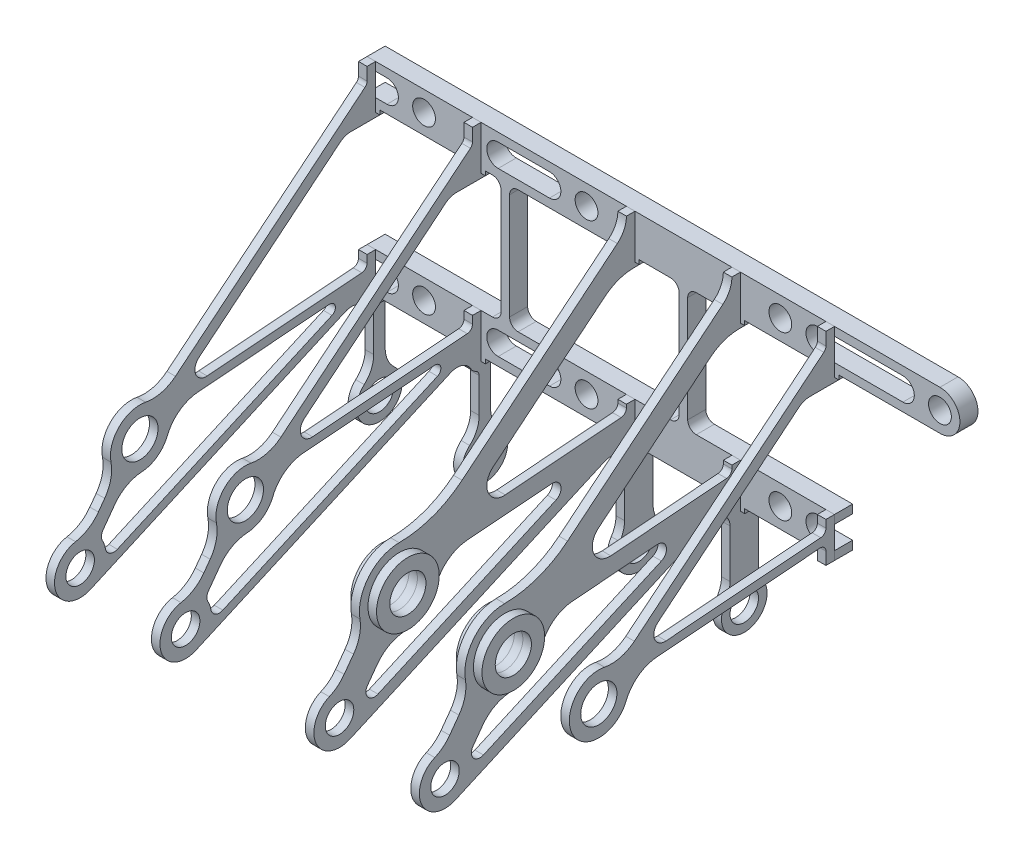
from build123d import *

# Parameters (mm, degrees)
SKETCH1_R                             = 4
BOSS_EXTRUDEMASTERCYLMNT_DEPTH        = 6.35
SKETCH7_R                             = 5
SKETCH7_R_2                           = 6.35
BOSS_EXTRUDEFLANGE1_DEPTH             = 3
BOSS_EXTRUDEFLANGE2_START             = -37
SKETCH7_2_R                           = 5
SKETCH7_2_R_2                         = 6.35
BOSS_EXTRUDEFLANGE2_DEPTH             = 3
BOSS_EXTRUDEFLANGE3_START             = -91
SKETCH7_3_R                           = 5
SKETCH7_3_R_2                         = 6.35
BOSS_EXTRUDEFLANGE3_DEPTH             = 3
BOSS_EXTRUDEFLANGE4_START             = -128
SKETCH7_4_R                           = 5
SKETCH7_4_R_2                         = 6.35
BOSS_EXTRUDEFLANGE4_DEPTH             = 3
BOSS_EXTRUDEFLANGE5_START             = -161
SKETCH7_5_R                           = 5
SKETCH7_5_R_2                         = 6.35
BOSS_EXTRUDEFLANGE5_DEPTH             = 3
SKETCH26_R                            = 11
SKETCH26_R_2                          = 6.35
BOSS_EXTRUDEBRAKEBUSH1_DEPTH          = 3
BOSS_EXTRUDEBRAKEBUSH2_START          = -3
SKETCH26_2_R                          = 11
SKETCH26_2_R_2                        = 6.35
BOSS_EXTRUDEBRAKEBUSH2_DEPTH          = 3
SKETCH27_R                            = 11
SKETCH27_R_2                          = 6.35
BOSS_EXTRUDEBRAKEBUSH3_DEPTH          = 3
BOSS_EXTRUDEBRAKEBUSH4_START          = -3
SKETCH27_2_R                          = 11
SKETCH27_2_R_2                        = 6.35
BOSS_EXTRUDEBRAKEBUSH4_DEPTH          = 3
CUT_EXTRUDELIGHTENCLUTCHFLANGES_START = -40
CUT_EXTRUDELIGHTENCLUTCHFLANGES_DEPTH = 40
EXTRUDETRIMFLANGE5_START              = 30
EXTRUDETRIMFLANGE5_DEPTH              = 3


with BuildPart() as part:
    # Sketch1 → Boss-ExtrudeMasterCylMnt (new body)
    with BuildSketch(Plane.XY):
        with BuildLine():
            Line((-20, 78.15), (-20, 75.15))
            Line((-20, 75.15), (-17, 75.15))
            Line((-17, 75.15), (-17, 73.65))
            Line((-17, 73.65), (-15.5, 73.65))
            Line((-15.5, 73.65), (-15.5, 75.15))
            Line((-15.5, 75.15), (15.5, 75.15))
            Line((15.5, 75.15), (15.5, 73.65))
            Line((15.5, 73.65), (17, 73.65))
            Line((17, 73.65), (17, 75.15))
            Line((17, 75.15), (20, 75.15))
            Line((20, 75.15), (20, 73.65))
            Line((20, 73.65), (21.5, 73.65))
            Line((21.5, 73.65), (21.5, 75.15))
            Line((21.5, 75.15), (24, 75.15))
            ThreePointArc((24, 75.15), (26.121320344, 74.271320344), (27, 72.15))
            Line((27, 72.15), (27, 35))
            ThreePointArc((27, 35), (26.121320344, 32.878679656), (24, 32))
            Line((24, 32), (-20, 32))
            Line((-20, 32), (-20, 29.01))
            Line((-20, 29.01), (-13, 29.01))
            ThreePointArc((-13, 29.01), (-9, 25.01), (-13, 21.01))
            Line((-13, 21.01), (-20, 21.01))
            Line((-20, 21.01), (-20, 18))
            Line((-20, 18), (-17, 18))
            Line((-17, 18), (-17, 16.5))
            Line((-17, 16.5), (-15.5, 16.5))
            Line((-15.5, 16.5), (-15.5, 18))
            Line((-15.5, 18), (15.5, 18))
            Line((15.5, 18), (15.5, 16.5))
            Line((15.5, 16.5), (17, 16.5))
            Line((17, 16.5), (17, 18))
            Line((17, 18), (20, 18))
            Line((20, 18), (20, 16.5))
            Line((20, 16.5), (21.5, 16.5))
            Line((21.5, 16.5), (21.5, 18))
            Line((21.5, 18), (69.5, 18))
            Line((69.5, 18), (69.5, 16.5))
            Line((69.5, 16.5), (71, 16.5))
            Line((71, 16.5), (71, 18))
            Line((71, 18), (74, 18))
            Line((74, 18), (74, 16.5))
            Line((74, 16.5), (75.5, 16.5))
            Line((75.5, 16.5), (75.5, 18))
            Line((75.5, 18), (106.5, 18))
            Line((106.5, 18), (106.5, 16.5))
            Line((106.5, 16.5), (108, 16.5))
            Line((108, 16.5), (108, 18))
            Line((108, 18), (111, 18))
            Line((111, 18), (111, 16.5))
            Line((111, 16.5), (112.5, 16.5))
            Line((112.5, 16.5), (112.5, 18))
            Line((112.5, 18), (139.5, 18))
            Line((139.5, 18), (144, 18))
            Line((144, 18), (144, 21.01))
            Line((144, 21.01), (138, 21.01))
            ThreePointArc((138, 21.01), (134, 25.01), (138, 29.01))
            Line((138, 29.01), (144, 29.01))
            Line((144, 29.01), (144, 32))
            Line((144, 32), (95.5, 32))
            ThreePointArc((95.5, 32), (93.378679656, 32.878679656), (92.5, 35))
            Line((92.5, 35), (92.5, 72.15))
            ThreePointArc((92.5, 72.15), (93.378679656, 74.271320344), (95.5, 75.15))
            Line((95.5, 75.15), (106.5, 75.15))
            Line((106.5, 75.15), (106.5, 73.65))
            Line((106.5, 73.65), (108, 73.65))
            Line((108, 73.65), (108, 75.15))
            Line((108, 75.15), (111, 75.15))
            Line((111, 75.15), (111, 73.65))
            Line((111, 73.65), (112.5, 73.65))
            Line((112.5, 73.65), (112.5, 75.15))
            Line((112.5, 75.15), (139.5, 75.15))
            Line((139.5, 75.15), (139.5, 73.65))
            Line((139.5, 73.65), (141, 73.65))
            Line((141, 73.65), (141, 75.15))
            Line((141, 75.15), (144, 75.15))
            Line((144, 75.15), (144, 73.65))
            Line((144, 73.65), (145.5, 73.65))
            Line((145.5, 73.65), (145.5, 75.15))
            Line((145.5, 75.15), (181, 75.15))
            ThreePointArc((181, 75.15), (188, 82.15), (181, 89.15))
            Line((181, 89.15), (-20, 89.15))
            Line((-20, 89.15), (-20, 86.15))
            Line((-20, 86.15), (-13, 86.15))
            ThreePointArc((-13, 86.15), (-9, 82.15), (-13, 78.15))
            Line((-13, 78.15), (-20, 78.15))
        make_face()
        with Locations((0, 25)):
            Circle(SKETCH1_R, mode=Mode.SUBTRACT)
        with BuildLine():
            Line((44, 21.01), (26, 21.01))
            ThreePointArc((26, 21.01), (22, 25.01), (26, 29.01))
            Line((26, 29.01), (44, 29.01))
            ThreePointArc((44, 29.01), (48, 25.01), (44, 21.01))
        make_face(mode=Mode.SUBTRACT)
        with Locations((57, 25)):
            Circle(SKETCH1_R, mode=Mode.SUBTRACT)
        with Locations((125, 25)):
            Circle(SKETCH1_R, mode=Mode.SUBTRACT)
        with BuildLine():
            Line((30, 35), (30, 72.15))
            ThreePointArc((30, 72.15), (30.878679656, 74.271320344), (33, 75.15))
            Line((33, 75.15), (69.5, 75.15))
            Line((69.5, 75.15), (69.5, 73.65))
            Line((69.5, 73.65), (71, 73.65))
            Line((71, 73.65), (71, 75.15))
            Line((71, 75.15), (74, 75.15))
            Line((74, 75.15), (74, 73.65))
            Line((74, 73.65), (75.5, 73.65))
            Line((75.5, 73.65), (75.5, 75.15))
            Line((75.5, 75.15), (86.5, 75.15))
            ThreePointArc((86.5, 75.15), (88.621320344, 74.271320344), (89.5, 72.15))
            Line((89.5, 72.15), (89.5, 35))
            ThreePointArc((89.5, 35), (88.621320344, 32.878679656), (86.5, 32))
            Line((86.5, 32), (33, 32))
            ThreePointArc((33, 32), (30.878679656, 32.878679656), (30, 35))
        make_face(mode=Mode.SUBTRACT)
        with Locations((0, 82.15)):
            Circle(SKETCH1_R, mode=Mode.SUBTRACT)
        with BuildLine():
            ThreePointArc((26, 78.15), (22, 82.15), (26, 86.15))
            Line((26, 86.15), (44, 86.15))
            ThreePointArc((44, 86.15), (48, 82.15), (44, 78.15))
            Line((44, 78.15), (26, 78.15))
        make_face(mode=Mode.SUBTRACT)
        with Locations((57, 82.15)):
            Circle(SKETCH1_R, mode=Mode.SUBTRACT)
        with Locations((125, 82.15)):
            Circle(SKETCH1_R, mode=Mode.SUBTRACT)
        with BuildLine():
            ThreePointArc((138, 78.15), (134, 82.15), (138, 86.15))
            Line((138, 86.15), (168, 86.15))
            ThreePointArc((168, 86.15), (172, 82.15), (168, 78.15))
            Line((168, 78.15), (138, 78.15))
        make_face(mode=Mode.SUBTRACT)
        with Locations((181, 82.15)):
            Circle(SKETCH1_R, mode=Mode.SUBTRACT)
    extrude(amount=BOSS_EXTRUDEMASTERCYLMNT_DEPTH)


with BuildPart() as body_2:
    # Sketch7 → Boss-ExtrudeFlange1 (new body)
    with BuildSketch(Plane.ZY.offset(20)):
        with BuildLine():
            Line((6.35, 89.15), (9.35, 89.15))
            ThreePointArc((9.35, 89.15), (10.186580835, 85.425817841), (12.535576646, 82.417226986))
            Line((12.535576646, 82.417226986), (67.005927029, 37.741380788))
            ThreePointArc((67.005927029, 37.741380788), (77.358033455, 31.867104728), (89.079803502, 29.799900421))
            ThreePointArc((89.079803502, 29.799900421), (99.727698532, 24.827460935), (102.835814605, 13.494216144))
            ThreePointArc((102.835814605, 13.494216144), (103.002588852, 8.482693213), (105.09610657, 3.926339485))
            Line((105.09610657, 3.926339485), (108.369409581, -0.568540919))
            ThreePointArc((108.369409581, -0.568540919), (110.696195364, -3.004680506), (113.58162057, -4.743366661))
            ThreePointArc((113.58162057, -4.743366661), (118.241680078, -16.615896777), (106.349889445, -21.226584524))
            Line((106.349889445, -21.226584524), (17.027839197, 18.405337748))
            ThreePointArc((17.027839197, 18.405337748), (12.274123626, 18.026623442), (10, 13.835013013))
            Line((10, 13.835013013), (10, -3.050125629))
            ThreePointArc((10, -3.050125629), (10.425728922, -5.936876975), (11.666666667, -8.577833613))
            ThreePointArc((11.666666667, -8.577833613), (5, -21), (-1.666666667, -8.577833613))
            ThreePointArc((-1.666666667, -8.577833613), (-0.425728922, -5.936876975), (0, -3.050125629))
            Line((0, -3.050125629), (0, 18))
            Line((0, 18), (6.35, 18))
            Line((6.35, 18), (6.35, 32))
            Line((6.35, 32), (9.35, 32))
            Line((9.35, 32), (9.35, 30.859486419))
            ThreePointArc((9.35, 30.859486419), (9.881953914, 29.501237293), (11.19484069, 28.865514106))
            Line((11.19484069, 28.865514106), (51.849686175, 25.701990855))
            ThreePointArc((51.849686175, 25.701990855), (57.882033206, 29.445611924), (56.120158964, 36.323090281))
            Line((56.120158964, 36.323090281), (16.863157181, 68.521153292))
            ThreePointArc((16.863157181, 68.521153292), (12.104525537, 71.215497879), (6.716504224, 72.15))
            Line((6.716504224, 72.15), (0, 72.15))
            Line((0, 72.15), (0, 75.15))
            Line((0, 75.15), (6.35, 75.15))
            Line((6.35, 75.15), (6.35, 89.15))
        make_face()
        with Locations(Location((5, -13, 0), (0, 0, 270))):
            Circle(SKETCH7_R, mode=Mode.SUBTRACT)
        with Locations(Location((110, -13, 0), (0, 0, 270))):
            Circle(SKETCH7_R, mode=Mode.SUBTRACT)
        with Locations(Location((89.027, 15.8, 0), (0, 0, 270))):
            Circle(SKETCH7_R_2, mode=Mode.SUBTRACT)
        with BuildLine():
            Line((96.516705924, -12.487574216), (34.065668531, 15.221761306))
            ThreePointArc((34.065668531, 15.221761306), (32.373883046, 18.699273572), (35.515111015, 20.954914618))
            Line((35.515111015, 20.954914618), (65.181839655, 18.646422612))
            ThreePointArc((65.181839655, 18.646422612), (71.74021255, 16.201526612), (76.00730309, 10.65339992))
            ThreePointArc((76.00730309, 10.65339992), (80.612199988, 4.611115303), (87.694923998, 1.863516458))
            ThreePointArc((87.694923998, 1.863516458), (92.778543875, 0.252938841), (96.752816338, -3.302663738))
            Line((96.752816338, -3.302663738), (100.158513908, -7.979347571))
            ThreePointArc((100.158513908, -7.979347571), (100.067094315, -11.630562367), (96.516705924, -12.487574216))
        make_face(mode=Mode.SUBTRACT)
    extrude(amount=-BOSS_EXTRUDEFLANGE1_DEPTH)


with BuildPart() as body_3:
    # Sketch7_2 → Boss-ExtrudeFlange2 (new body)
    with BuildSketch(Plane.ZY.offset(20).offset(BOSS_EXTRUDEFLANGE2_START)):
        with BuildLine():
            Line((6.35, 89.15), (9.35, 89.15))
            ThreePointArc((9.35, 89.15), (10.186580835, 85.425817841), (12.535576646, 82.417226986))
            Line((12.535576646, 82.417226986), (67.005927029, 37.741380788))
            ThreePointArc((67.005927029, 37.741380788), (77.358033455, 31.867104728), (89.079803502, 29.799900421))
            ThreePointArc((89.079803502, 29.799900421), (99.727698532, 24.827460935), (102.835814605, 13.494216144))
            ThreePointArc((102.835814605, 13.494216144), (103.002588852, 8.482693213), (105.09610657, 3.926339485))
            Line((105.09610657, 3.926339485), (108.369409581, -0.568540919))
            ThreePointArc((108.369409581, -0.568540919), (110.696195364, -3.004680506), (113.58162057, -4.743366661))
            ThreePointArc((113.58162057, -4.743366661), (118.241680078, -16.615896777), (106.349889445, -21.226584524))
            Line((106.349889445, -21.226584524), (17.027839197, 18.405337748))
            ThreePointArc((17.027839197, 18.405337748), (12.274123626, 18.026623442), (10, 13.835013013))
            Line((10, 13.835013013), (10, -3.050125629))
            ThreePointArc((10, -3.050125629), (10.425728922, -5.936876975), (11.666666667, -8.577833613))
            ThreePointArc((11.666666667, -8.577833613), (5, -21), (-1.666666667, -8.577833613))
            ThreePointArc((-1.666666667, -8.577833613), (-0.425728922, -5.936876975), (0, -3.050125629))
            Line((0, -3.050125629), (0, 18))
            Line((0, 18), (6.35, 18))
            Line((6.35, 18), (6.35, 32))
            Line((6.35, 32), (9.35, 32))
            Line((9.35, 32), (9.35, 30.859486419))
            ThreePointArc((9.35, 30.859486419), (9.881953914, 29.501237293), (11.19484069, 28.865514106))
            Line((11.19484069, 28.865514106), (51.849686175, 25.701990855))
            ThreePointArc((51.849686175, 25.701990855), (57.882033206, 29.445611924), (56.120158964, 36.323090281))
            Line((56.120158964, 36.323090281), (16.863157181, 68.521153292))
            ThreePointArc((16.863157181, 68.521153292), (12.104525537, 71.215497879), (6.716504224, 72.15))
            Line((6.716504224, 72.15), (0, 72.15))
            Line((0, 72.15), (0, 75.15))
            Line((0, 75.15), (6.35, 75.15))
            Line((6.35, 75.15), (6.35, 89.15))
        make_face()
        with Locations(Location((5, -13, 0), (0, 0, 270))):
            Circle(SKETCH7_2_R, mode=Mode.SUBTRACT)
        with Locations(Location((110, -13, 0), (0, 0, 270))):
            Circle(SKETCH7_2_R, mode=Mode.SUBTRACT)
        with Locations(Location((89.027, 15.8, 0), (0, 0, 270))):
            Circle(SKETCH7_2_R_2, mode=Mode.SUBTRACT)
        with BuildLine():
            Line((96.516705924, -12.487574216), (34.065668531, 15.221761306))
            ThreePointArc((34.065668531, 15.221761306), (32.373883046, 18.699273572), (35.515111015, 20.954914618))
            Line((35.515111015, 20.954914618), (65.181839655, 18.646422612))
            ThreePointArc((65.181839655, 18.646422612), (71.74021255, 16.201526612), (76.00730309, 10.65339992))
            ThreePointArc((76.00730309, 10.65339992), (80.612199988, 4.611115303), (87.694923998, 1.863516458))
            ThreePointArc((87.694923998, 1.863516458), (92.778543875, 0.252938841), (96.752816338, -3.302663738))
            Line((96.752816338, -3.302663738), (100.158513908, -7.979347571))
            ThreePointArc((100.158513908, -7.979347571), (100.067094315, -11.630562367), (96.516705924, -12.487574216))
        make_face(mode=Mode.SUBTRACT)
    extrude(amount=-BOSS_EXTRUDEFLANGE2_DEPTH)


with BuildPart() as body_4:
    # Sketch7_3 → Boss-ExtrudeFlange3 (new body)
    with BuildSketch(Plane.ZY.offset(20).offset(BOSS_EXTRUDEFLANGE3_START)):
        with BuildLine():
            Line((6.35, 89.15), (9.35, 89.15))
            ThreePointArc((9.35, 89.15), (10.186580835, 85.425817841), (12.535576646, 82.417226986))
            Line((12.535576646, 82.417226986), (67.005927029, 37.741380788))
            ThreePointArc((67.005927029, 37.741380788), (77.358033455, 31.867104728), (89.079803502, 29.799900421))
            ThreePointArc((89.079803502, 29.799900421), (99.727698532, 24.827460935), (102.835814605, 13.494216144))
            ThreePointArc((102.835814605, 13.494216144), (103.002588852, 8.482693213), (105.09610657, 3.926339485))
            Line((105.09610657, 3.926339485), (108.369409581, -0.568540919))
            ThreePointArc((108.369409581, -0.568540919), (110.696195364, -3.004680506), (113.58162057, -4.743366661))
            ThreePointArc((113.58162057, -4.743366661), (118.241680078, -16.615896777), (106.349889445, -21.226584524))
            Line((106.349889445, -21.226584524), (17.027839197, 18.405337748))
            ThreePointArc((17.027839197, 18.405337748), (12.274123626, 18.026623442), (10, 13.835013013))
            Line((10, 13.835013013), (10, -3.050125629))
            ThreePointArc((10, -3.050125629), (10.425728922, -5.936876975), (11.666666667, -8.577833613))
            ThreePointArc((11.666666667, -8.577833613), (5, -21), (-1.666666667, -8.577833613))
            ThreePointArc((-1.666666667, -8.577833613), (-0.425728922, -5.936876975), (0, -3.050125629))
            Line((0, -3.050125629), (0, 18))
            Line((0, 18), (6.35, 18))
            Line((6.35, 18), (6.35, 32))
            Line((6.35, 32), (9.35, 32))
            Line((9.35, 32), (9.35, 30.859486419))
            ThreePointArc((9.35, 30.859486419), (9.881953914, 29.501237293), (11.19484069, 28.865514106))
            Line((11.19484069, 28.865514106), (51.849686175, 25.701990855))
            ThreePointArc((51.849686175, 25.701990855), (57.882033206, 29.445611924), (56.120158964, 36.323090281))
            Line((56.120158964, 36.323090281), (16.863157181, 68.521153292))
            ThreePointArc((16.863157181, 68.521153292), (12.104525537, 71.215497879), (6.716504224, 72.15))
            Line((6.716504224, 72.15), (0, 72.15))
            Line((0, 72.15), (0, 75.15))
            Line((0, 75.15), (6.35, 75.15))
            Line((6.35, 75.15), (6.35, 89.15))
        make_face()
        with Locations(Location((5, -13, 0), (0, 0, 270))):
            Circle(SKETCH7_3_R, mode=Mode.SUBTRACT)
        with Locations(Location((110, -13, 0), (0, 0, 270))):
            Circle(SKETCH7_3_R, mode=Mode.SUBTRACT)
        with Locations(Location((89.027, 15.8, 0), (0, 0, 270))):
            Circle(SKETCH7_3_R_2, mode=Mode.SUBTRACT)
        with BuildLine():
            Line((96.516705924, -12.487574216), (34.065668531, 15.221761306))
            ThreePointArc((34.065668531, 15.221761306), (32.373883046, 18.699273572), (35.515111015, 20.954914618))
            Line((35.515111015, 20.954914618), (65.181839655, 18.646422612))
            ThreePointArc((65.181839655, 18.646422612), (71.74021255, 16.201526612), (76.00730309, 10.65339992))
            ThreePointArc((76.00730309, 10.65339992), (80.612199988, 4.611115303), (87.694923998, 1.863516458))
            ThreePointArc((87.694923998, 1.863516458), (92.778543875, 0.252938841), (96.752816338, -3.302663738))
            Line((96.752816338, -3.302663738), (100.158513908, -7.979347571))
            ThreePointArc((100.158513908, -7.979347571), (100.067094315, -11.630562367), (96.516705924, -12.487574216))
        make_face(mode=Mode.SUBTRACT)
    extrude(amount=-BOSS_EXTRUDEFLANGE3_DEPTH)


with BuildPart() as body_5:
    # Sketch7_4 → Boss-ExtrudeFlange4 (new body)
    with BuildSketch(Plane.ZY.offset(20).offset(BOSS_EXTRUDEFLANGE4_START)):
        with BuildLine():
            Line((6.35, 89.15), (9.35, 89.15))
            ThreePointArc((9.35, 89.15), (10.186580835, 85.425817841), (12.535576646, 82.417226986))
            Line((12.535576646, 82.417226986), (67.005927029, 37.741380788))
            ThreePointArc((67.005927029, 37.741380788), (77.358033455, 31.867104728), (89.079803502, 29.799900421))
            ThreePointArc((89.079803502, 29.799900421), (99.727698532, 24.827460935), (102.835814605, 13.494216144))
            ThreePointArc((102.835814605, 13.494216144), (103.002588852, 8.482693213), (105.09610657, 3.926339485))
            Line((105.09610657, 3.926339485), (108.369409581, -0.568540919))
            ThreePointArc((108.369409581, -0.568540919), (110.696195364, -3.004680506), (113.58162057, -4.743366661))
            ThreePointArc((113.58162057, -4.743366661), (118.241680078, -16.615896777), (106.349889445, -21.226584524))
            Line((106.349889445, -21.226584524), (17.027839197, 18.405337748))
            ThreePointArc((17.027839197, 18.405337748), (12.274123626, 18.026623442), (10, 13.835013013))
            Line((10, 13.835013013), (10, -3.050125629))
            ThreePointArc((10, -3.050125629), (10.425728922, -5.936876975), (11.666666667, -8.577833613))
            ThreePointArc((11.666666667, -8.577833613), (5, -21), (-1.666666667, -8.577833613))
            ThreePointArc((-1.666666667, -8.577833613), (-0.425728922, -5.936876975), (0, -3.050125629))
            Line((0, -3.050125629), (0, 18))
            Line((0, 18), (6.35, 18))
            Line((6.35, 18), (6.35, 32))
            Line((6.35, 32), (9.35, 32))
            Line((9.35, 32), (9.35, 30.859486419))
            ThreePointArc((9.35, 30.859486419), (9.881953914, 29.501237293), (11.19484069, 28.865514106))
            Line((11.19484069, 28.865514106), (51.849686175, 25.701990855))
            ThreePointArc((51.849686175, 25.701990855), (57.882033206, 29.445611924), (56.120158964, 36.323090281))
            Line((56.120158964, 36.323090281), (16.863157181, 68.521153292))
            ThreePointArc((16.863157181, 68.521153292), (12.104525537, 71.215497879), (6.716504224, 72.15))
            Line((6.716504224, 72.15), (0, 72.15))
            Line((0, 72.15), (0, 75.15))
            Line((0, 75.15), (6.35, 75.15))
            Line((6.35, 75.15), (6.35, 89.15))
        make_face()
        with Locations(Location((5, -13, 0), (0, 0, 270))):
            Circle(SKETCH7_4_R, mode=Mode.SUBTRACT)
        with Locations(Location((110, -13, 0), (0, 0, 270))):
            Circle(SKETCH7_4_R, mode=Mode.SUBTRACT)
        with Locations(Location((89.027, 15.8, 0), (0, 0, 270))):
            Circle(SKETCH7_4_R_2, mode=Mode.SUBTRACT)
        with BuildLine():
            Line((96.516705924, -12.487574216), (34.065668531, 15.221761306))
            ThreePointArc((34.065668531, 15.221761306), (32.373883046, 18.699273572), (35.515111015, 20.954914618))
            Line((35.515111015, 20.954914618), (65.181839655, 18.646422612))
            ThreePointArc((65.181839655, 18.646422612), (71.74021255, 16.201526612), (76.00730309, 10.65339992))
            ThreePointArc((76.00730309, 10.65339992), (80.612199988, 4.611115303), (87.694923998, 1.863516458))
            ThreePointArc((87.694923998, 1.863516458), (92.778543875, 0.252938841), (96.752816338, -3.302663738))
            Line((96.752816338, -3.302663738), (100.158513908, -7.979347571))
            ThreePointArc((100.158513908, -7.979347571), (100.067094315, -11.630562367), (96.516705924, -12.487574216))
        make_face(mode=Mode.SUBTRACT)
    extrude(amount=-BOSS_EXTRUDEFLANGE4_DEPTH)


with BuildPart() as body_6:
    # Sketch7_5 → Boss-ExtrudeFlange5 (new body)
    with BuildSketch(Plane.ZY.offset(20).offset(BOSS_EXTRUDEFLANGE5_START)):
        with BuildLine():
            Line((6.35, 89.15), (9.35, 89.15))
            ThreePointArc((9.35, 89.15), (10.186580835, 85.425817841), (12.535576646, 82.417226986))
            Line((12.535576646, 82.417226986), (67.005927029, 37.741380788))
            ThreePointArc((67.005927029, 37.741380788), (77.358033455, 31.867104728), (89.079803502, 29.799900421))
            ThreePointArc((89.079803502, 29.799900421), (99.727698532, 24.827460935), (102.835814605, 13.494216144))
            ThreePointArc((102.835814605, 13.494216144), (103.002588852, 8.482693213), (105.09610657, 3.926339485))
            Line((105.09610657, 3.926339485), (108.369409581, -0.568540919))
            ThreePointArc((108.369409581, -0.568540919), (110.696195364, -3.004680506), (113.58162057, -4.743366661))
            ThreePointArc((113.58162057, -4.743366661), (118.241680078, -16.615896777), (106.349889445, -21.226584524))
            Line((106.349889445, -21.226584524), (17.027839197, 18.405337748))
            ThreePointArc((17.027839197, 18.405337748), (12.274123626, 18.026623442), (10, 13.835013013))
            Line((10, 13.835013013), (10, -3.050125629))
            ThreePointArc((10, -3.050125629), (10.425728922, -5.936876975), (11.666666667, -8.577833613))
            ThreePointArc((11.666666667, -8.577833613), (5, -21), (-1.666666667, -8.577833613))
            ThreePointArc((-1.666666667, -8.577833613), (-0.425728922, -5.936876975), (0, -3.050125629))
            Line((0, -3.050125629), (0, 18))
            Line((0, 18), (6.35, 18))
            Line((6.35, 18), (6.35, 32))
            Line((6.35, 32), (9.35, 32))
            Line((9.35, 32), (9.35, 30.859486419))
            ThreePointArc((9.35, 30.859486419), (9.881953914, 29.501237293), (11.19484069, 28.865514106))
            Line((11.19484069, 28.865514106), (51.849686175, 25.701990855))
            ThreePointArc((51.849686175, 25.701990855), (57.882033206, 29.445611924), (56.120158964, 36.323090281))
            Line((56.120158964, 36.323090281), (16.863157181, 68.521153292))
            ThreePointArc((16.863157181, 68.521153292), (12.104525537, 71.215497879), (6.716504224, 72.15))
            Line((6.716504224, 72.15), (0, 72.15))
            Line((0, 72.15), (0, 75.15))
            Line((0, 75.15), (6.35, 75.15))
            Line((6.35, 75.15), (6.35, 89.15))
        make_face()
        with Locations(Location((5, -13, 0), (0, 0, 270))):
            Circle(SKETCH7_5_R, mode=Mode.SUBTRACT)
        with Locations(Location((110, -13, 0), (0, 0, 270))):
            Circle(SKETCH7_5_R, mode=Mode.SUBTRACT)
        with Locations(Location((89.027, 15.8, 0), (0, 0, 270))):
            Circle(SKETCH7_5_R_2, mode=Mode.SUBTRACT)
        with BuildLine():
            Line((96.516705924, -12.487574216), (34.065668531, 15.221761306))
            ThreePointArc((34.065668531, 15.221761306), (32.373883046, 18.699273572), (35.515111015, 20.954914618))
            Line((35.515111015, 20.954914618), (65.181839655, 18.646422612))
            ThreePointArc((65.181839655, 18.646422612), (71.74021255, 16.201526612), (76.00730309, 10.65339992))
            ThreePointArc((76.00730309, 10.65339992), (80.612199988, 4.611115303), (87.694923998, 1.863516458))
            ThreePointArc((87.694923998, 1.863516458), (92.778543875, 0.252938841), (96.752816338, -3.302663738))
            Line((96.752816338, -3.302663738), (100.158513908, -7.979347571))
            ThreePointArc((100.158513908, -7.979347571), (100.067094315, -11.630562367), (96.516705924, -12.487574216))
        make_face(mode=Mode.SUBTRACT)
    extrude(amount=-BOSS_EXTRUDEFLANGE5_DEPTH)

    # Sketch14 → ExtrudeTrimFlange5 (cut)
    with BuildSketch(Plane(origin=(111, 0, 0), x_dir=(0, 0, -1), z_dir=(1, 0, 0)).offset(EXTRUDETRIMFLANGE5_START)):
        with BuildLine():
            Line((-9.346873068, 22.334034632), (-9.346873068, 18))
            Line((-9.346873068, 18), (25.703053845, 18))
            Line((25.703053845, 18), (25.703053845, -44.096398774))
            Line((25.703053845, -44.096398774), (-131.303156721, -44.096398774))
            Line((-131.303156721, -44.096398774), (-131.303156721, 89.15))
            Line((-131.303156721, 89.15), (-9.35, 89.15))
            Line((-9.35, 89.15), (-9.35, 84.682952268))
            ThreePointArc((-9.35, 84.682952268), (-9.542147235, 83.827576105), (-10.08166838, 83.136558107))
            Line((-10.08166838, 83.136558107), (-76.567816795, 28.60551654))
            ThreePointArc((-76.567816795, 28.60551654), (-81.512756497, 26.11153632), (-87.048925323, 25.959218502))
            ThreePointArc((-87.048925323, 25.959218502), (-99.355090486, 16.473087603), (-88.38422086, 5.469978946))
            ThreePointArc((-88.38422086, 5.469978946), (-82.964478912, 7.411416207), (-79.420428917, 11.948209244))
            ThreePointArc((-79.420428917, 11.948209244), (-75.151308369, 17.457083831), (-68.617917323, 19.883581495))
            Line((-68.617917323, 19.883581495), (-11.502032378, 24.328006946))
            ThreePointArc((-11.502032378, 24.328006946), (-9.988623941, 23.802080718), (-9.346873068, 22.334034632))
        make_face()
        with BuildLine():
            Line((-65.444512551, 23.13958623), (-11.19484069, 27.360979675))
            ThreePointArc((-11.19484069, 27.360979675), (-9.881953914, 27.996702862), (-9.35, 29.354951989))
            Line((-9.35, 29.354951989), (-9.35, 32))
            Line((-9.35, 32), (-6.716504224, 72.15))
            Line((-6.716504224, 72.15), (-15.023526002, 72.15))
            ThreePointArc((-15.023526002, 72.15), (-17.044033994, 71.799561705), (-18.828520861, 70.789182485))
            Line((-18.828520861, 70.789182485), (-68.29149441, 30.22031918))
            ThreePointArc((-68.29149441, 30.22031918), (-69.466077238, 25.635333609), (-65.444512551, 23.13958623))
        make_face()
    extrude(amount=EXTRUDETRIMFLANGE5_DEPTH, mode=Mode.SUBTRACT)


with BuildPart() as body_7:
    # Sketch26 → Boss-ExtrudeBrakeBush1 (new body)
    with BuildSketch(Plane.ZY.offset(-71)):
        with Locations(Location((89.027, 15.8, 0), (0, 0, 270))):
            Circle(SKETCH26_R)
        with Locations(Location((89.027, 15.8, 0), (0, 0, 270))):
            Circle(SKETCH26_R_2, mode=Mode.SUBTRACT)
    extrude(amount=BOSS_EXTRUDEBRAKEBUSH1_DEPTH)


with BuildPart() as body_8:
    # Sketch26_2 → Boss-ExtrudeBrakeBush2 (new body)
    with BuildSketch(Plane.ZY.offset(-71).offset(BOSS_EXTRUDEBRAKEBUSH2_START)):
        with Locations(Location((89.027, 15.8, 0), (0, 0, 270))):
            Circle(SKETCH26_2_R)
        with Locations(Location((89.027, 15.8, 0), (0, 0, 270))):
            Circle(SKETCH26_2_R_2, mode=Mode.SUBTRACT)
    extrude(amount=-BOSS_EXTRUDEBRAKEBUSH2_DEPTH)


with BuildPart() as body_9:
    # Sketch27 → Boss-ExtrudeBrakeBush3 (new body)
    with BuildSketch(Plane.ZY.offset(-108)):
        with Locations(Location((89.027, 15.8, 0), (0, 0, 270))):
            Circle(SKETCH27_R)
        with Locations(Location((89.027, 15.8, 0), (0, 0, 270))):
            Circle(SKETCH27_R_2, mode=Mode.SUBTRACT)
    extrude(amount=BOSS_EXTRUDEBRAKEBUSH3_DEPTH)


with BuildPart() as body_10:
    # Sketch27_2 → Boss-ExtrudeBrakeBush4 (new body)
    with BuildSketch(Plane.ZY.offset(-108).offset(BOSS_EXTRUDEBRAKEBUSH4_START)):
        with Locations(Location((89.027, 15.8, 0), (0, 0, 270))):
            Circle(SKETCH27_2_R)
        with Locations(Location((89.027, 15.8, 0), (0, 0, 270))):
            Circle(SKETCH27_2_R_2, mode=Mode.SUBTRACT)
    extrude(amount=-BOSS_EXTRUDEBRAKEBUSH4_DEPTH)


with BuildPart() as cut_extrudelightenclutchflanges_tool:
    # Sketch33 → Cut-ExtrudeLightenClutchFlanges (new body)
    with BuildSketch(Plane.ZY.offset(20).offset(CUT_EXTRUDELIGHTENCLUTCHFLANGES_START)):
        with BuildLine():
            Line((18.828520861, 70.789182485), (68.29149441, 30.22031918))
            ThreePointArc((68.29149441, 30.22031918), (69.466077238, 25.635333609), (65.444512551, 23.13958623))
            Line((65.444512551, 23.13958623), (11.19484069, 27.360979675))
            ThreePointArc((11.19484069, 27.360979675), (9.881953914, 27.996702862), (9.35, 29.354951989))
            Line((9.35, 29.354951989), (9.35, 32))
            Line((9.35, 32), (6.716504224, 72.15))
            Line((6.716504224, 72.15), (15.023526002, 72.15))
            ThreePointArc((15.023526002, 72.15), (17.044033994, 71.799561705), (18.828520861, 70.789182485))
        make_face()
        with BuildLine():
            Line((101.386850936, 3.923696499), (103.606726851, 0.875375975))
            ThreePointArc((103.606726851, 0.875375975), (107.12255052, -2.405810841), (111.606314368, -4.14450712))
            ThreePointArc((111.606314368, -4.14450712), (112.611192336, -4.387121585), (113.58162057, -4.743366661))
            Line((113.58162057, -4.743366661), (131.303156721, -4.743366661))
            Line((131.303156721, -4.743366661), (131.303156721, 89.15))
            Line((131.303156721, 89.15), (9.35, 89.15))
            Line((9.35, 89.15), (9.35, 84.682952268))
            ThreePointArc((9.35, 84.682952268), (9.542147235, 83.827576105), (10.08166838, 83.136558107))
            Line((10.08166838, 83.136558107), (76.567816795, 28.60551654))
            ThreePointArc((76.567816795, 28.60551654), (81.512756497, 26.11153632), (87.048925323, 25.959218502))
            ThreePointArc((87.048925323, 25.959218502), (96.344718141, 23.119392134), (99.186670687, 13.824249122))
            ThreePointArc((99.186670687, 13.824249122), (99.255566074, 8.644812441), (101.386850936, 3.923696499))
        make_face()
        with BuildLine():
            Line((101.961552845, -5.359099049), (97.861772269, 0.270695477))
            ThreePointArc((97.861772269, 0.270695477), (93.703801858, 3.929062333), (88.38422086, 5.469978946))
            ThreePointArc((88.38422086, 5.469978946), (82.964478912, 7.411416207), (79.420428917, 11.948209244))
            ThreePointArc((79.420428917, 11.948209244), (75.151308369, 17.457083831), (68.617917323, 19.883581495))
            Line((68.617917323, 19.883581495), (22.603952173, 23.464120219))
            ThreePointArc((22.603952173, 23.464120219), (20.509800194, 21.960359521), (21.637657184, 19.642018011))
            Line((21.637657184, 19.642018011), (96.94611801, -13.772117219))
            ThreePointArc((96.94611801, -13.772117219), (99.585641203, -13.6710555), (101.122116147, -11.522441783))
            ThreePointArc((101.122116147, -11.522441783), (101.509997023, -10.013388299), (102.152336285, -8.59384814))
            ThreePointArc((102.152336285, -8.59384814), (102.531244106, -6.94849971), (101.961552845, -5.359099049))
        make_face()
        with BuildLine():
            Line((3, 18), (3, 0.416407865))
            ThreePointArc((3, 0.416407865), (2.128709292, -3.66607504), (-0.333333333, -7.03715206))
            ThreePointArc((-0.333333333, -7.03715206), (-1.049249946, -7.764871053), (-1.666666667, -8.577833613))
            Line((-1.666666667, -8.577833613), (-7.696883635, -8.577833613))
            Line((-7.696883635, -8.577833613), (-7.696883635, 18))
            Line((-7.696883635, 18), (3, 18))
        make_face()
        with BuildLine():
            Line((7, 0.416407865), (7, 12.541171389))
            ThreePointArc((7, 12.541171389), (7.304881634, 13.602573162), (8.126573724, 14.340373029))
            ThreePointArc((8.126573724, 14.340373029), (9.145440973, 15.044565424), (9.905191564, 16.022704699))
            ThreePointArc((9.905191564, 16.022704699), (13.004164055, 18.596175128), (17.027839197, 18.405337748))
            Line((17.027839197, 18.405337748), (17.027839197, -8.577833613))
            Line((17.027839197, -8.577833613), (11.666666667, -8.577833613))
            ThreePointArc((11.666666667, -8.577833613), (11.049249946, -7.764871053), (10.333333333, -7.03715206))
            ThreePointArc((10.333333333, -7.03715206), (7.871290708, -3.66607504), (7, 0.416407865))
        make_face()
    extrude(amount=CUT_EXTRUDELIGHTENCLUTCHFLANGES_DEPTH)


with BuildPart() as body_2_1:
    add(body_2.part)

    # Cut-ExtrudeLightenClutchFlanges: cut by cut_extrudelightenclutchflanges_tool
    add(cut_extrudelightenclutchflanges_tool.part, mode=Mode.SUBTRACT)


with BuildPart() as body_3_1:
    add(body_3.part)

    # Cut-ExtrudeLightenClutchFlanges: cut by cut_extrudelightenclutchflanges_tool
    add(cut_extrudelightenclutchflanges_tool.part, mode=Mode.SUBTRACT)


solid = Compound([part.part, body_4.part, body_5.part, body_6.part, body_7.part, body_8.part, body_9.part, body_10.part, body_2_1.part, body_3_1.part])
